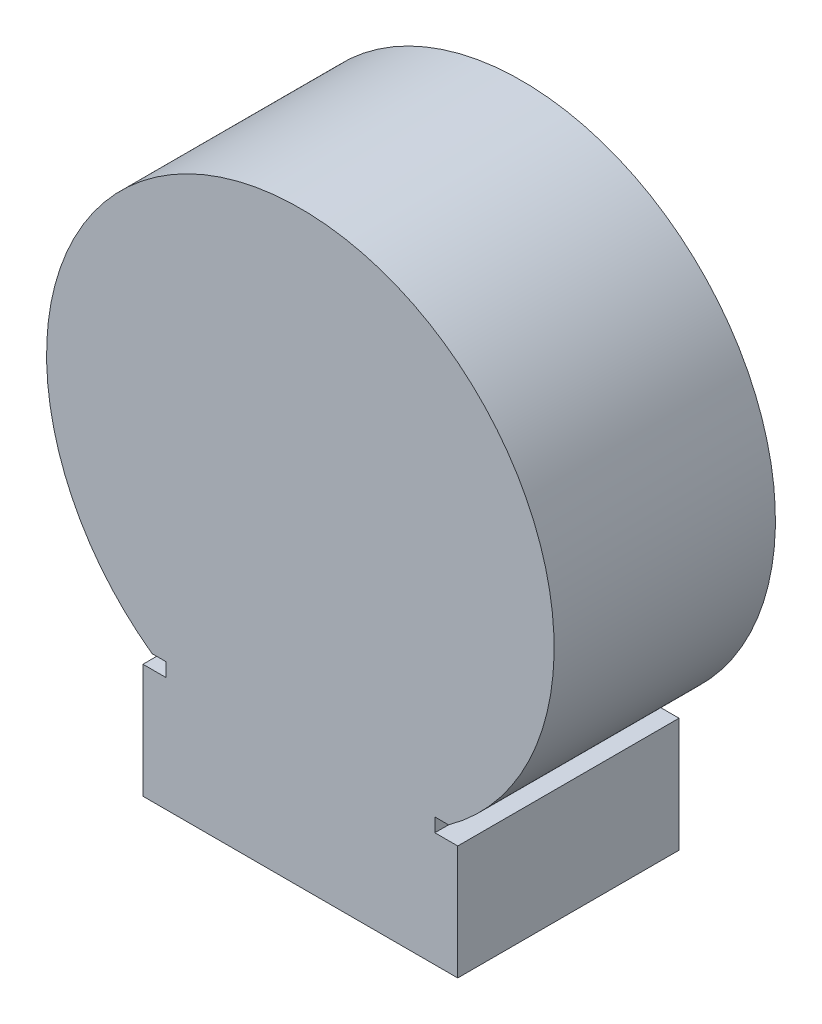
from build123d import *

# Parameters (mm, degrees)
BOSS_EXTRUDE1_DEPTH = 12.29


with BuildPart() as part:
    # Sketch2 → Boss-Extrude1 (new body)
    with BuildSketch(Plane.XY):
        with BuildLine():
            Line((-8.74, 3.175), (-7.47, 3.175))
            Line((-7.47, 3.175), (-7.47, 3.937))
            Line((-7.47, 3.937), (-8.232, 3.937))
            ThreePointArc((-8.232, 3.937), (0, 29.470311879), (8.232, 3.937))
            Line((8.232, 3.937), (7.47, 3.937))
            Line((7.47, 3.937), (7.47, 3.175))
            Line((7.47, 3.175), (8.74, 3.175))
            Line((8.74, 3.175), (8.74, -3.175))
            Line((8.74, -3.175), (-8.74, -3.175))
            Line((-8.74, -3.175), (-8.74, 3.175))
        make_face()
    extrude(amount=BOSS_EXTRUDE1_DEPTH)


solid = part.part
